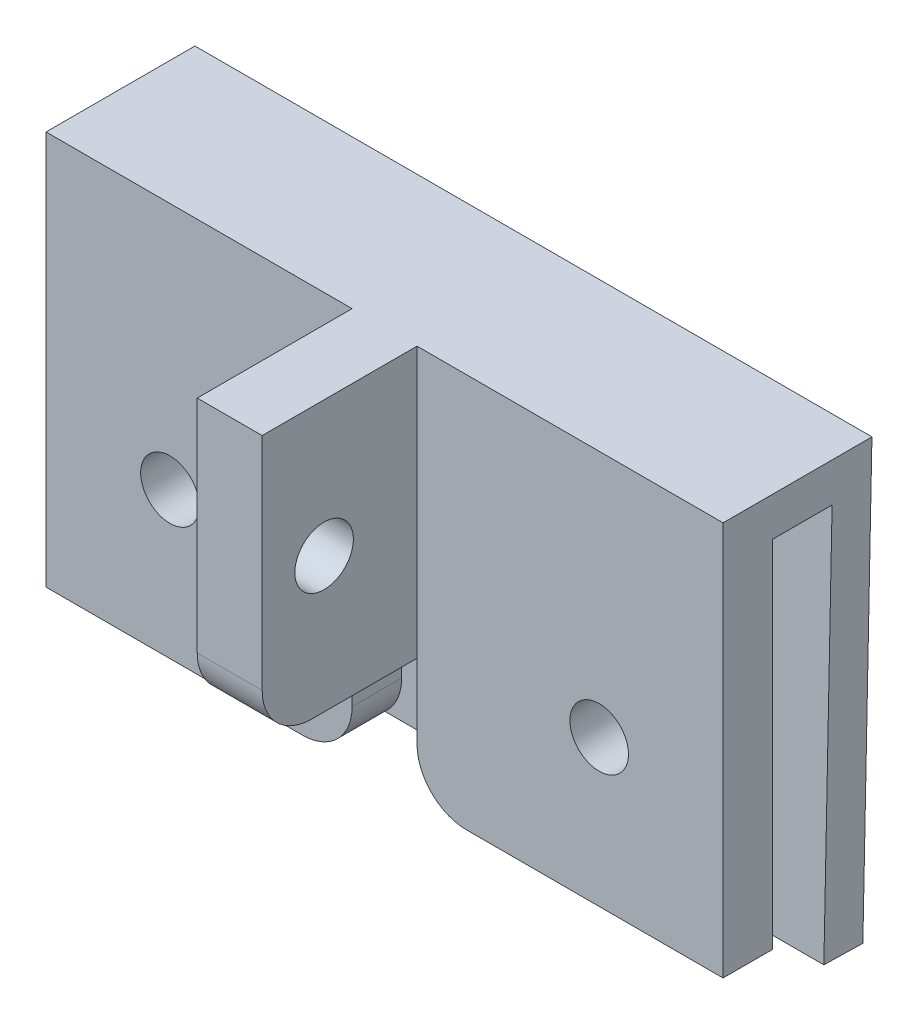
from build123d import *

# Parameters (mm, degrees)
SKETCH1_R           = 1.5
BOSS_EXTRUDE1_DEPTH = 2.54
SKETCH2_W           = 3.3274
SKETCH2_H           = 13.8539982
BOSS_EXTRUDE2_DEPTH = 7.9375
SKETCH3_R           = 1.5
CUT_EXTRUDE1_DEPTH  = 20.0137
FILLET1_R           = 2.54
FILLET3_R           = 2.54
BOSS_EXTRUDE3_DEPTH = 34.7


with BuildPart() as part:
    # Sketch1 → Boss-Extrude1 (new body)
    with BuildSketch(Plane.XY):
        Polygon((17.35, 10.1019991), (-17.35, 10.1019991), (-17.35, -10.1019991), (-1.6637, -10.1019991), (-1.6637, -3.7519991), (1.6637, -3.7519991), (1.6637, -10.1019991), (17.35, -10.1019991), align=None)
        with Locations((-11, -2.5980009)):
            Circle(SKETCH1_R, mode=Mode.SUBTRACT)
        with Locations((11, -2.5980009)):
            Circle(SKETCH1_R, mode=Mode.SUBTRACT)
    extrude(amount=BOSS_EXTRUDE1_DEPTH)

    # Sketch2 → Boss-Extrude2 (add)
    with BuildSketch(Plane.XY.offset(2.54)):
        with Locations((0, 3.175)):
            Rectangle(SKETCH2_W, SKETCH2_H)
    extrude(amount=BOSS_EXTRUDE2_DEPTH)

    # Sketch3 → Cut-Extrude1 (cut, through all)
    with BuildSketch(Plane.ZY.offset(1.6637)):
        with Locations((7.3025, 3.175)):
            Circle(SKETCH3_R)
    extrude(amount=-CUT_EXTRUDE1_DEPTH, mode=Mode.SUBTRACT)

    # Fillet1
    fillet1_edges = [part.edges().sort_by_distance(p)[0] for p in [
        (0, -3.7519991, 10.4775),
    ]]
    fillet(fillet1_edges, radius=FILLET1_R)

    # Fillet3
    fillet3_edges = [part.edges().sort_by_distance(p)[0] for p in [
        (-1.6637, -10.1019991, 1.27),
        (1.6637, -10.1019991, 1.27),
    ]]
    fillet(fillet3_edges, radius=FILLET3_R)

    # Sketch4 → Boss-Extrude3 (add)
    with BuildSketch(Plane(origin=(17.35, 0, 0), x_dir=(0, 0, -1), z_dir=(1, 0, 0))):
        Polygon((2.625150229, -12.101561201), (2.667, -10.1019991), (4.666562101, -10.143848871), (4.62471233, -12.143410972), align=None)
        Polygon((5.090296931, 10.1019991), (0, 10.1019991), (0, 8.1019991), (3.048, 8.1019991), (2.667, -10.1019991), (4.666562101, -10.143848871), align=None)
    extrude(amount=-BOSS_EXTRUDE3_DEPTH)


solid = part.part
